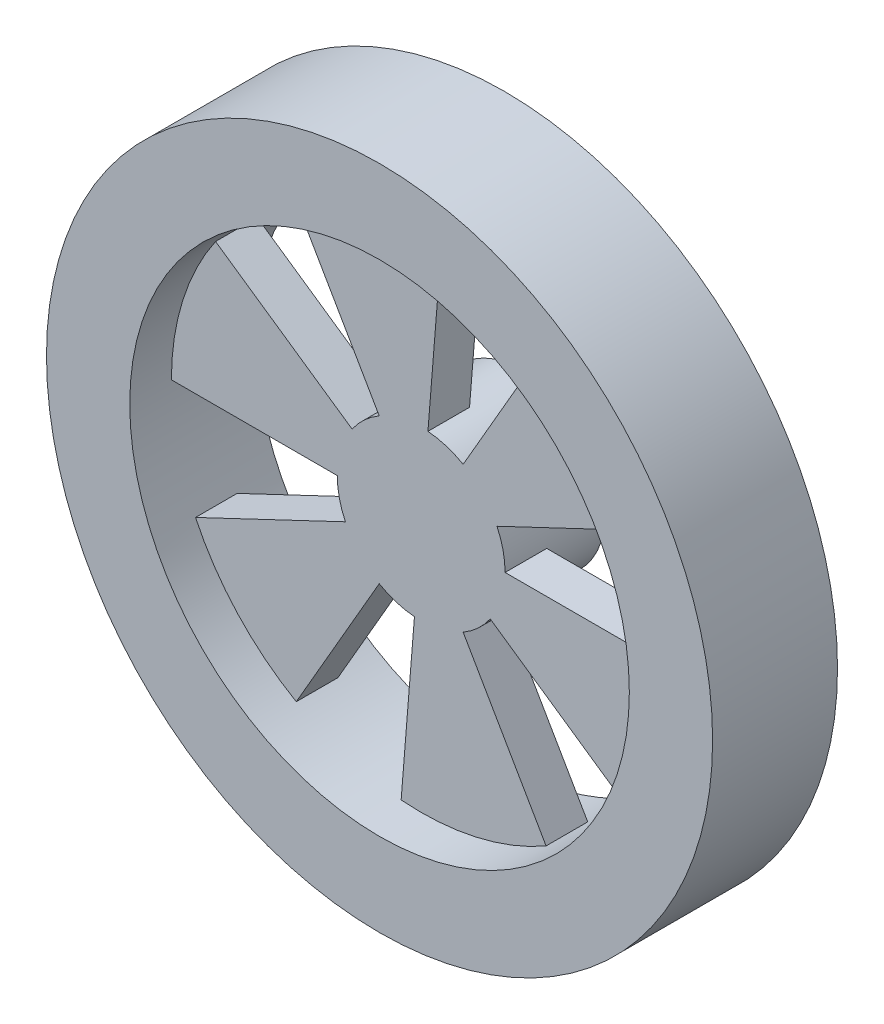
from build123d import *

# Parameters (mm, degrees)
SKETCH1_R           = 40
BOSS_EXTRUDE1_DEPTH = 15
SKETCH2_R           = 7.5
SKETCH2_R_2         = 1
BOSS_EXTRUDE2_DEPTH = 20
SKETCH4_R           = 3.175
CUT_EXTRUDE1_DEPTH  = 1.6
SKETCH5_W           = 2
SKETCH5_H           = 2.576429586
SKETCH5_W_2         = 1.5
SKETCH5_H_2         = 1
SKETCH5_4_W         = 1.5
SKETCH5_4_H         = 1
CUT_EXTRUDE2_START  = -5
SKETCH6_R           = 30
SKETCH6_R_2         = 10.076429586
CUT_EXTRUDE2_DEPTH  = 5
SKETCH7_R           = 30
CUT_EXTRUDE3_DEPTH  = 5
CUT_EXTRUDE4_START  = -5
CUT_EXTRUDE4_DEPTH  = 5


with BuildPart() as part:
    # Sketch1 → Boss-Extrude1 (new body)
    with BuildSketch(Plane.XY):
        Circle(SKETCH1_R)
    extrude(amount=BOSS_EXTRUDE1_DEPTH)

    # Sketch2 → Boss-Extrude2 (add)
    with BuildSketch(Plane.XY):
        Circle(SKETCH2_R)
        Circle(SKETCH2_R_2, mode=Mode.SUBTRACT)
    extrude(amount=-BOSS_EXTRUDE2_DEPTH)

    # Sketch4 → Cut-Extrude1 (cut)
    with BuildSketch(Plane(origin=(0, 0, -20), x_dir=(-1, 0, 0), z_dir=(0, 0, -1))):
        Circle(SKETCH4_R)
    extrude(amount=-CUT_EXTRUDE1_DEPTH, mode=Mode.SUBTRACT)

    # Sketch5 → Revolve2 (revolve)
    with BuildSketch(Plane(origin=(0, 0, 0), x_dir=(0, 0, -1), z_dir=(1, 0, 0))):
        with Locations((1, 8.788214793)):
            Rectangle(SKETCH5_W, SKETCH5_H)
        with Locations((12.75, 7)):
            Rectangle(SKETCH5_W_2, SKETCH5_H_2)
    revolve(axis=Axis((0, 0, -21.75), (0, 0, 1)))

    # Sketch5_4 → Cut-Revolve1 (revolve, cut)
    with BuildSketch(Plane(origin=(0, 0, 0), x_dir=(0, 0, -1), z_dir=(1, 0, 0))):
        with Locations((12.75, 7)):
            Rectangle(SKETCH5_4_W, SKETCH5_4_H)
    revolve(axis=Axis((0, 0, -21.75), (0, 0, 1)), mode=Mode.SUBTRACT)

    # Sketch6 → Cut-Extrude2 (cut)
    with BuildSketch(Plane(origin=(0, 0, 0), x_dir=(-1, 0, 0), z_dir=(0, 0, -1)).offset(CUT_EXTRUDE2_START)):
        Circle(SKETCH6_R)
        Circle(SKETCH6_R_2, mode=Mode.SUBTRACT)
    extrude(amount=CUT_EXTRUDE2_DEPTH, mode=Mode.SUBTRACT)

    # Sketch7 → Cut-Extrude3 (cut)
    with BuildSketch(Plane.XY.offset(15)):
        Circle(SKETCH7_R)
    extrude(amount=-CUT_EXTRUDE3_DEPTH, mode=Mode.SUBTRACT)

    # Sketch8 → Cut-Extrude4 (cut)
    with BuildSketch(Plane(origin=(0, 0, 5), x_dir=(-1, 0, 0), z_dir=(0, 0, -1)).offset(CUT_EXTRUDE4_START)):
        with BuildLine():
            Line((-10.076429586, 0), (-30, 0))
            ThreePointArc((-30, 0), (-29.266323118, 6.59411337), (-27.101177924, 12.865696838))
            Line((-27.101177924, 12.865696838), (-9.102770368, 4.321342942))
            ThreePointArc((-9.102770368, 4.321342942), (-9.830001471, 2.214837302), (-10.076429586, 0))
        make_face()
        with BuildLine():
            Line((-2.408568663, 29.903156974), (-0.808992418, 10.043901854))
            ThreePointArc((-0.808992418, 10.043901854), (-2.996895367, 9.620449644), (-5.038214793, 8.726444001))
            Line((-5.038214793, 8.726444001), (-15, 25.980762114))
            ThreePointArc((-15, 25.980762114), (-8.922491865, 28.642435981), (-2.408568663, 29.903156974))
        make_face()
        with BuildLine():
            Line((24.692609261, 17.037460136), (8.29377795, 5.722558913))
            ThreePointArc((8.29377795, 5.722558913), (6.833106104, 7.405612342), (5.038214793, 8.726444001))
            Line((5.038214793, 8.726444001), (15, 25.980762114))
            ThreePointArc((15, 25.980762114), (20.343831253, 22.048322611), (24.692609261, 17.037460136))
        make_face()
        with BuildLine():
            Line((27.101177924, -12.865696838), (9.102770368, -4.321342942))
            ThreePointArc((9.102770368, -4.321342942), (9.830001471, -2.214837302), (10.076429586, 0))
            Line((10.076429586, 0), (30, 0))
            ThreePointArc((30, 0), (29.266323118, -6.59411337), (27.101177924, -12.865696838))
        make_face()
        with BuildLine():
            Line((2.408568663, -29.903156974), (0.808992418, -10.043901854))
            ThreePointArc((0.808992418, -10.043901854), (2.996895367, -9.620449644), (5.038214793, -8.726444001))
            Line((5.038214793, -8.726444001), (15, -25.980762114))
            ThreePointArc((15, -25.980762114), (8.922491865, -28.642435981), (2.408568663, -29.903156974))
        make_face()
        with BuildLine():
            Line((-24.692609261, -17.037460136), (-8.29377795, -5.722558913))
            ThreePointArc((-8.29377795, -5.722558913), (-6.833106104, -7.405612342), (-5.038214793, -8.726444001))
            Line((-5.038214793, -8.726444001), (-15, -25.980762114))
            ThreePointArc((-15, -25.980762114), (-20.343831253, -22.048322611), (-24.692609261, -17.037460136))
        make_face()
    extrude(amount=CUT_EXTRUDE4_DEPTH, mode=Mode.SUBTRACT)


solid = part.part
